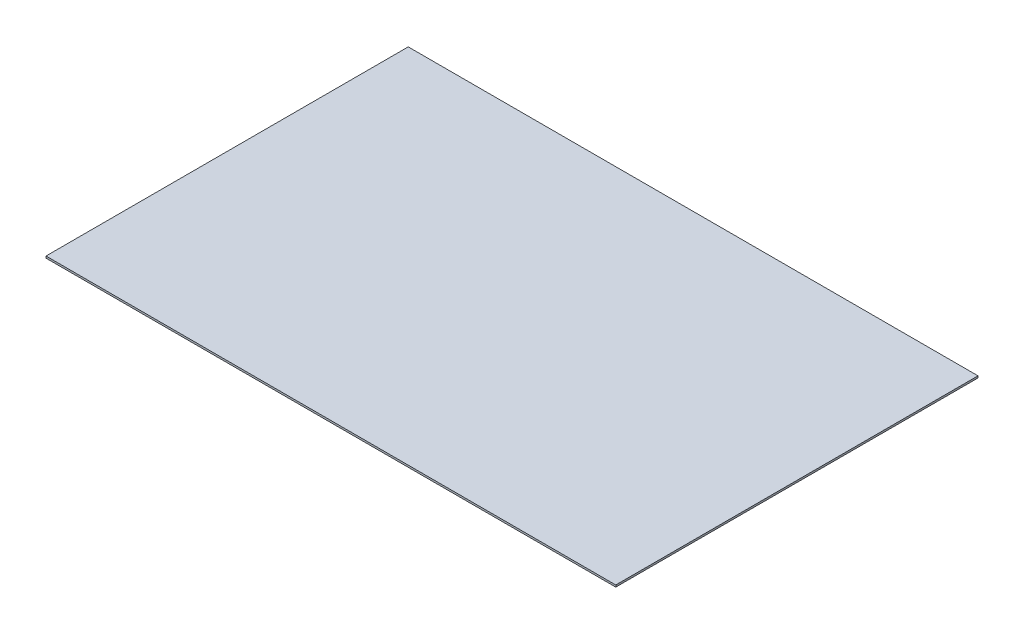
from build123d import *

# Parameters (mm, degrees)
SKETCH1_W           = 479.425
SKETCH1_H           = 304.8
BOSS_EXTRUDE1_DEPTH = 1.5875


with BuildPart() as part:
    # Sketch1 → Boss-Extrude1 (new body)
    with BuildSketch(Plane(origin=(0, 0, 0), x_dir=(1, 0, 0), z_dir=(0, 1, 0))):
        Rectangle(SKETCH1_W, SKETCH1_H)
    extrude(amount=BOSS_EXTRUDE1_DEPTH)


solid = part.part
